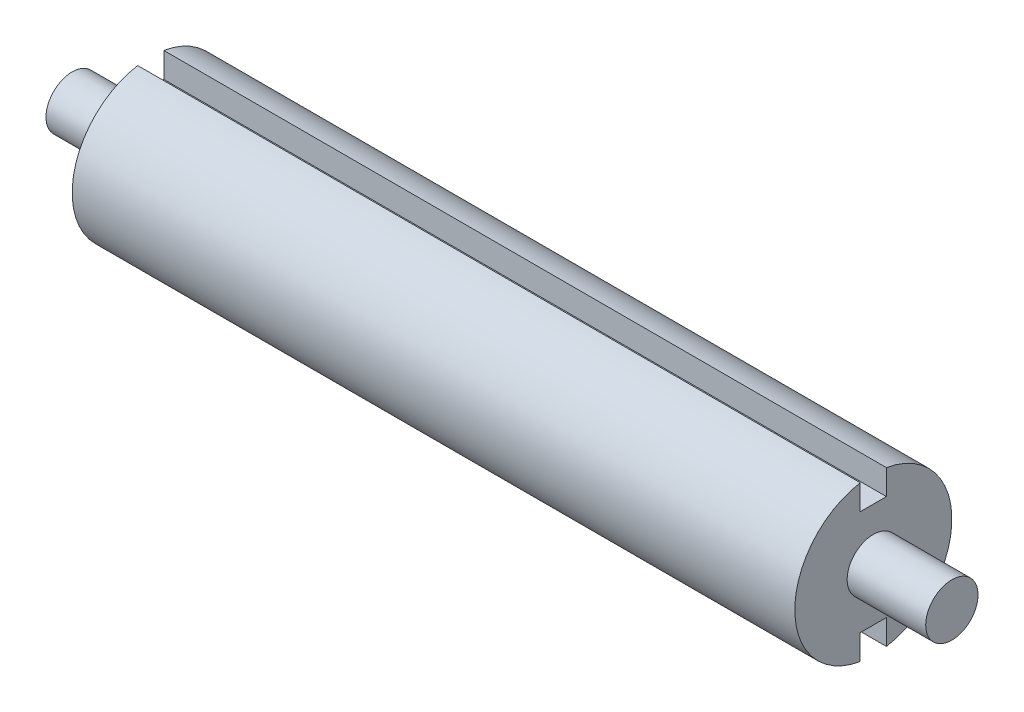
from build123d import *

# Parameters (mm, degrees)
SKETCH2_W          = 6.35
SKETCH2_H          = 6.35
CUT_EXTRUDE1_DEPTH = 195.31


with BuildPart() as part:
    # Sketch1 → Revolve1 (revolve)
    with BuildSketch(Plane(origin=(0, 0, 0), x_dir=(1, 0, 0), z_dir=(0, 1, 0))):
        Polygon((-106.68, 0), (106.68, 0), (106.68, 6.35), (87.63, 6.35), (87.63, 19.05), (-87.63, 19.05), (-87.63, 6.35), (-106.68, 6.35), align=None)
    revolve(axis=Axis((-106.68, 0, 0), (1, 0, 0)))

    # Sketch2 → Cut-Extrude1 (cut, through all)
    with BuildSketch(Plane(origin=(87.63, 0, 0), x_dir=(0, 0, -1), z_dir=(1, 0, 0))):
        with Locations((0, 15.875)):
            Rectangle(SKETCH2_W, SKETCH2_H)
        with Locations((0, -15.875)):
            Rectangle(SKETCH2_W, SKETCH2_H)
    extrude(amount=-CUT_EXTRUDE1_DEPTH, mode=Mode.SUBTRACT)


solid = part.part
